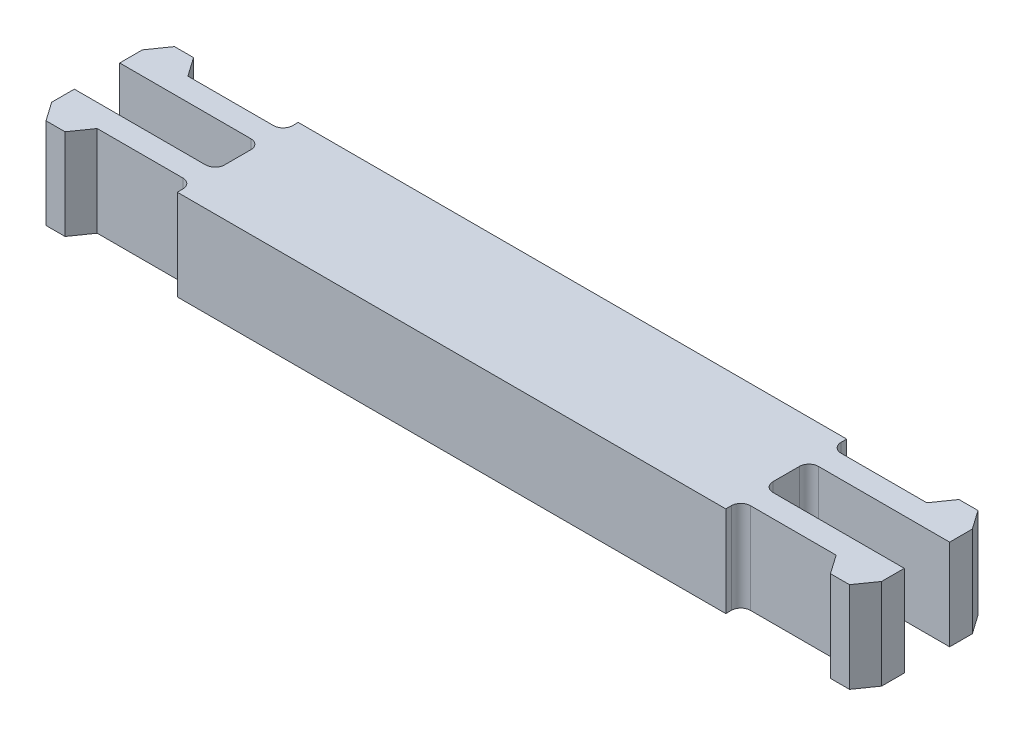
from build123d import *

# Parameters (mm, degrees)
SKETCH1_W            = 57.6
SKETCH1_H            = 12.7
BOSS_EXTRUDE1_DEPTH  = 9.525
BOSS_EXTRUDE2_DEPTH  = 9.525
MIRROR2_COPY_1_DEPTH = 9.525
FILLET1_R            = 1


with BuildPart() as part:
    # Sketch1 → Boss-Extrude1 (new body)
    with BuildSketch(Plane(origin=(0, 0, 0), x_dir=(1, 0, 0), z_dir=(0, 1, 0))):
        Rectangle(SKETCH1_W, SKETCH1_H)
    extrude(amount=BOSS_EXTRUDE1_DEPTH)

    # Sketch2 → Boss-Extrude2 (add)
    with BuildSketch(Plane(origin=(0, 9.525, 0), x_dir=(1, 0, 0), z_dir=(0, 1, 0))):
        Polygon((-28.8, 4.7625), (-38.8, 4.7625), (-40.189474334, 6.746875), (-42.189474334, 6.746875), (-43.578948667, 4.7625), (-43.578948667, 2.38125), (-28.8, 2.38125), align=None)
    boss_extrude2 = extrude(amount=-BOSS_EXTRUDE2_DEPTH)

    # Mirror1: Boss-Extrude2 across plane
    add(boss_extrude2.mirror(Plane(origin=(0, 0, 0), x_dir=(0, 0, 1), z_dir=(1, 0, 0))))

    # Mirror2: Boss-Extrude2 across plane
    add(boss_extrude2.mirror(Plane.XY))

    # Mirror2 copy 1 sketch → Mirror2 copy 1 (add)
    with BuildSketch(Plane(origin=(0, 9.525, 0), x_dir=(-1, 0, 0), z_dir=(0, 1, 0))):
        Polygon((-28.8, 4.7625), (-38.8, 4.7625), (-40.189474334, 6.746875), (-42.189474334, 6.746875), (-43.578948667, 4.7625), (-43.578948667, 2.38125), (-28.8, 2.38125), align=None)
    extrude(amount=-MIRROR2_COPY_1_DEPTH)

    # Fillet1
    fillet1_edges = [part.edges().sort_by_distance(p)[0] for p in [
        (-28.8, 4.7625, -4.7625),
        (-28.8, 4.7625, -2.38125),
        (28.8, 4.7625, -4.7625),
        (28.8, 4.7625, -2.38125),
        (-28.8, 4.7625, 4.7625),
        (-28.8, 4.7625, 2.38125),
        (28.8, 4.7625, 4.7625),
        (28.8, 4.7625, 2.38125),
    ]]
    fillet(fillet1_edges, radius=FILLET1_R)


solid = part.part
